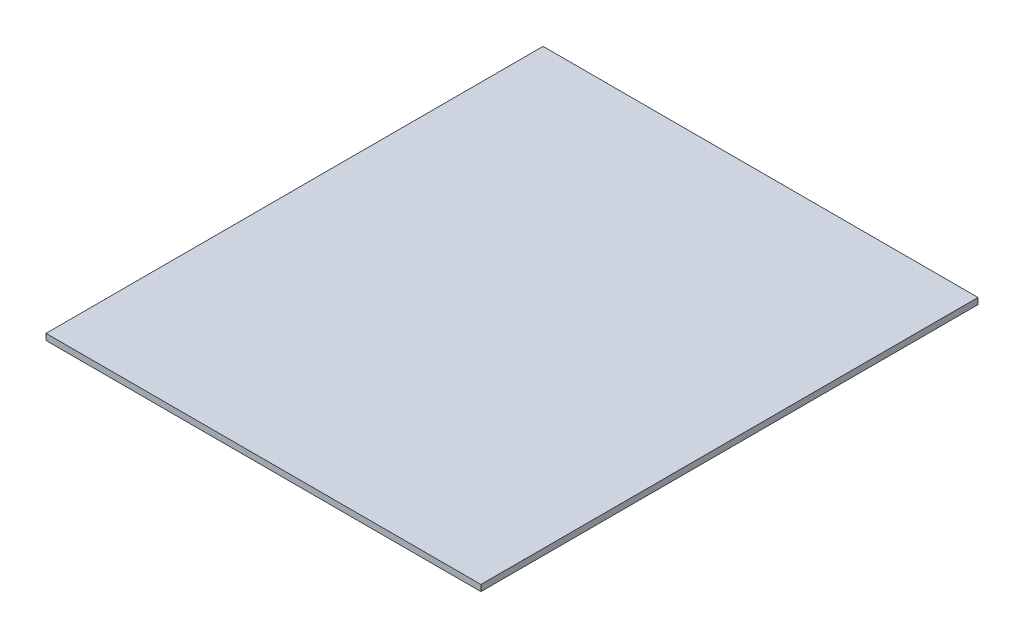
from build123d import *

# Parameters (mm, degrees)
SKETCH1_W           = 35
SKETCH1_H           = 40
BOSS_EXTRUDE1_DEPTH = 0.5
SCALE1_SCALE        = 10


with BuildPart() as part:
    # Sketch1 → Boss-Extrude1 (new body)
    with BuildSketch(Plane(origin=(0, 0, 0), x_dir=(1, 0, 0), z_dir=(0, 1, 0))):
        with Locations((-17.5, -20)):
            Rectangle(SKETCH1_W, SKETCH1_H)
    extrude(amount=BOSS_EXTRUDE1_DEPTH)


with BuildPart() as part_1:
    # Scale1: scaled about (-17.5, 0.25, 20)
    add(part.part.scale(SCALE1_SCALE).moved(Location((157.5, -2.25, -180))))


solid = part_1.part
